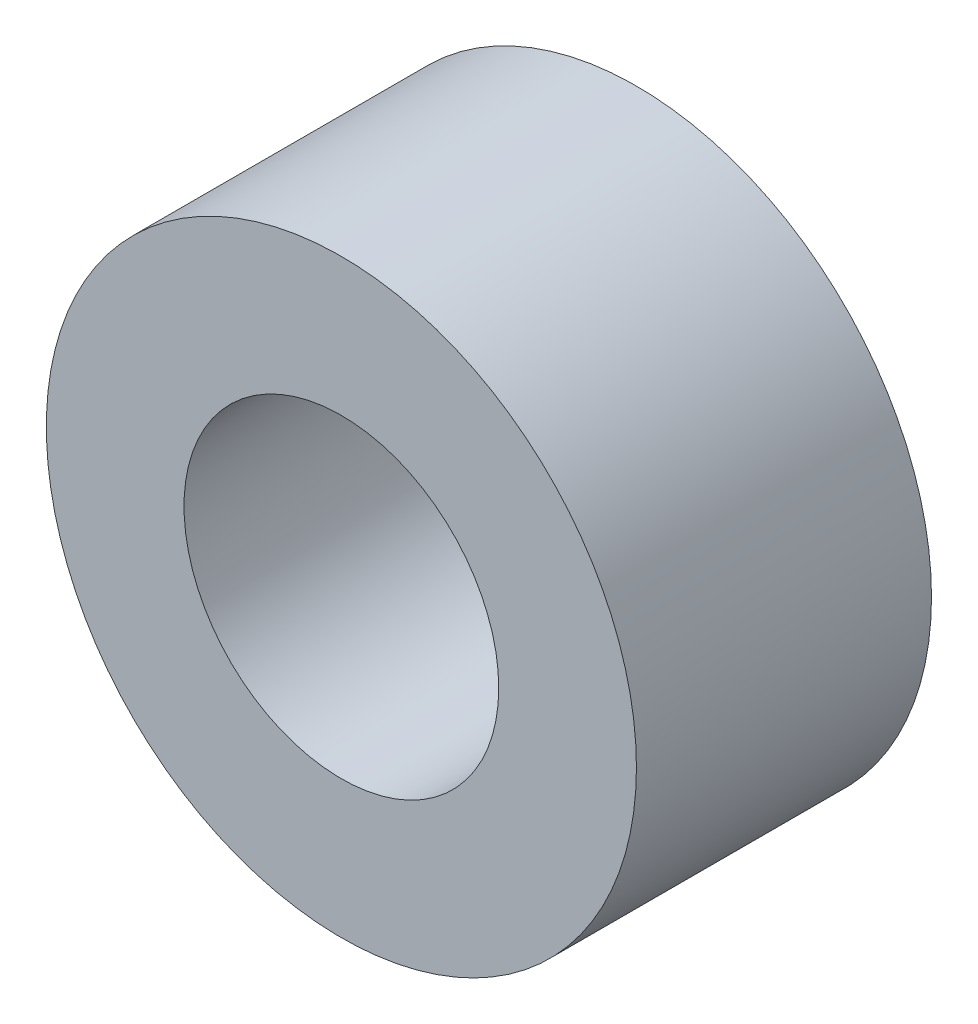
from build123d import *

# Parameters (mm, degrees)
SKETCH1_R      = 3
SKETCH1_R_2    = 1.6
EXTRUDE1_DEPTH = 1.5


with BuildPart() as part:
    # Sketch1 → Extrude1 (new body, symmetric)
    with BuildSketch(Plane.XY):
        Circle(SKETCH1_R)
        Circle(SKETCH1_R_2, mode=Mode.SUBTRACT)
    extrude(amount=EXTRUDE1_DEPTH, both=True)


solid = part.part
